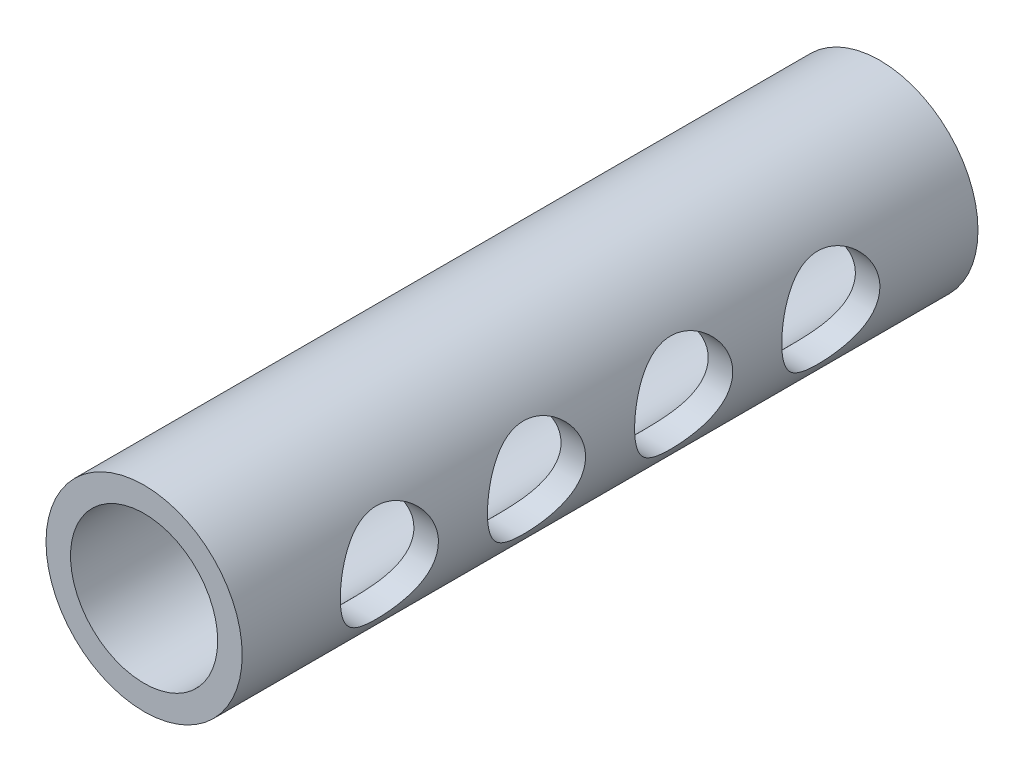
from build123d import *

# Parameters (mm, degrees)
SKETCH1_R           = 4
BOSS_EXTRUDE1_DEPTH = 30
SKETCH2_R           = 3
CUT_EXTRUDE1_DEPTH  = 31
CUT_EXTRUDE2_START  = 5
SKETCH3_R           = 2
CUT_EXTRUDE2_DEPTH  = 4


with BuildPart() as part:
    # Sketch1 → Boss-Extrude1 (new body)
    with BuildSketch(Plane.XY):
        Circle(SKETCH1_R)
    extrude(amount=BOSS_EXTRUDE1_DEPTH)

    # Sketch2 → Cut-Extrude1 (cut, through all)
    with BuildSketch(Plane.XY.offset(30)):
        Circle(SKETCH2_R)
    extrude(amount=-CUT_EXTRUDE1_DEPTH, mode=Mode.SUBTRACT)

    # Sketch3 → Cut-Extrude2 (cut)
    with BuildSketch(Plane(origin=(0, 0, 0), x_dir=(0, 0, -1), z_dir=(1, 0, 0)).offset(CUT_EXTRUDE2_START)):
        with Locations((-6, 0)):
            Circle(SKETCH3_R)
        with Locations((-12, 0)):
            Circle(SKETCH3_R)
        with Locations((-18, 0)):
            Circle(SKETCH3_R)
        with Locations((-24, 0)):
            Circle(SKETCH3_R)
    extrude(amount=-CUT_EXTRUDE2_DEPTH, mode=Mode.SUBTRACT)


solid = part.part
